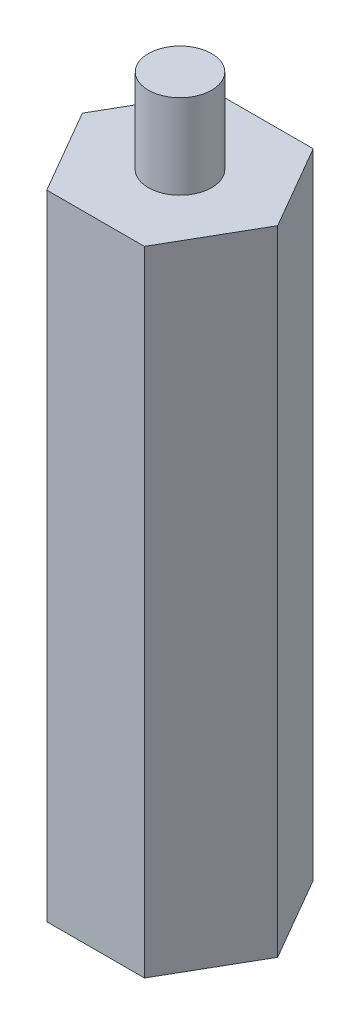
from build123d import *

# Parameters (mm, degrees)
EXTRUDE_1_DEPTH     = 60
SKETCH_2_R          = 3
EXTRUDE_2_DEPTH     = 8
SKETCH_3_R          = 3
CUT_EXTRUDE_1_DEPTH = 8


with BuildPart() as part:
    # 草图1 → 凸台-拉伸1 (new body)
    with BuildSketch(Plane(origin=(0, 0, 0), x_dir=(1, 0, 0), z_dir=(0, 1, 0))):
        Polygon((4.610693432, 8.004676097), (-4.626906133, 7.995315689), (-9.237599565, -0.009360407), (-4.610693432, -8.004676097), (4.626906133, -7.995315689), (9.237599565, 0.009360407), align=None)
    extrude(amount=EXTRUDE_1_DEPTH)

    # 草图2 → 凸台-拉伸2 (add)
    with BuildSketch(Plane(origin=(0, 60, 0), x_dir=(1, 0, 0), z_dir=(0, 1, 0))):
        Circle(SKETCH_2_R)
    extrude(amount=EXTRUDE_2_DEPTH)

    # 草图3 → 切除-拉伸1 (cut)
    with BuildSketch(Plane.XZ):
        Circle(SKETCH_3_R)
    extrude(amount=-CUT_EXTRUDE_1_DEPTH, mode=Mode.SUBTRACT)


solid = part.part
